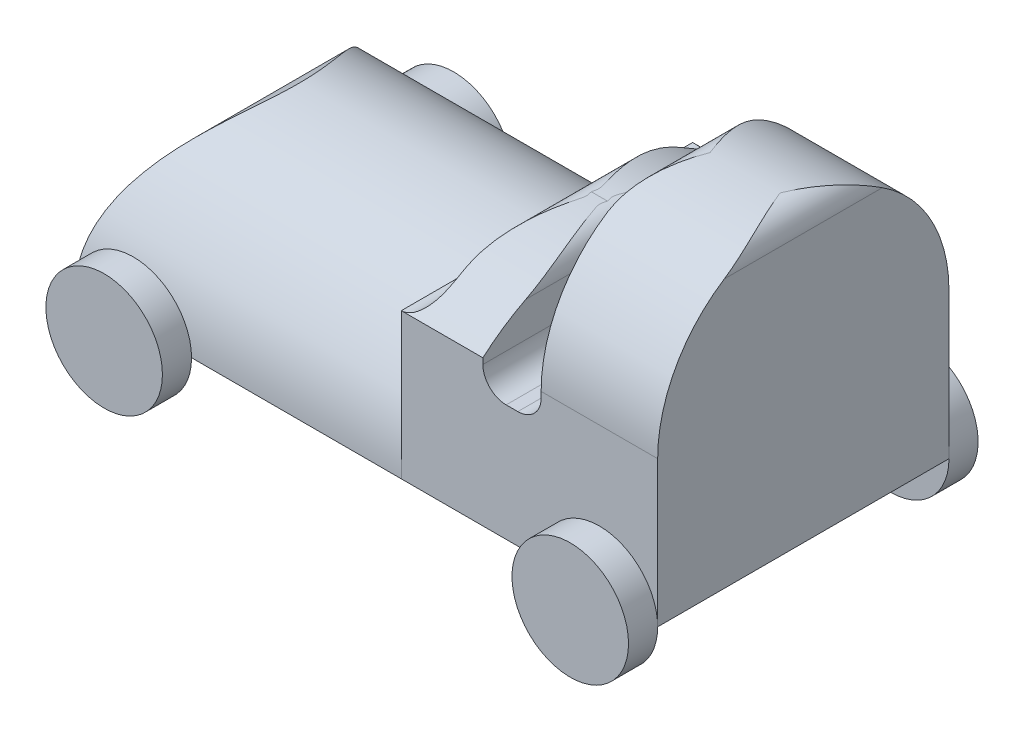
from build123d import *

# Parameters (mm, degrees)
SKETCH1_W               = 50
SKETCH1_H               = 25
BOSS_EXTRUDE1_DEPTH     = 25
CUT_EXTRUDE2_DEPTH      = 25
CUT_EXTRUDE3_DEPTH      = 49.79805324
CUT_EXTRUDE3_DEPTH_BACK = 49.79805324
CUT_EXTRUDE5_DEPTH      = 3
CUT_EXTRUDE5_DEPTH_BACK = 28
CUT_EXTRUDE9_DEPTH      = 7
SKETCH9_R               = 5
BOSS_EXTRUDE2_DEPTH     = 2.5
SKETCH10_R              = 5
BOSS_EXTRUDE3_DEPTH     = 2.5


with BuildPart() as part:
    # Sketch1 → Boss-Extrude1 (new body)
    with BuildSketch(Plane.XY):
        Rectangle(SKETCH1_W, SKETCH1_H)
    extrude(amount=BOSS_EXTRUDE1_DEPTH)

    # Sketch2 → Cut-Extrude2 (cut)
    with BuildSketch(Plane.XY.offset(25)):
        with BuildLine():
            Line((-25, 12.5), (-25, -12.5))
            ThreePointArc((-25, -12.5), (-23.216910184, -5.406814173), (-18.291561976, 0))
            Line((-18.291561976, 0), (3, 0))
            ThreePointArc((3, 0), (4.414213562, 0.585786438), (5, 2))
            Line((5, 2), (5, 2.5))
            ThreePointArc((5, 2.5), (5.585786438, 3.914213562), (7, 4.5))
            Line((7, 4.5), (8, 4.5))
            ThreePointArc((8, 4.5), (9.414213562, 3.914213562), (10, 2.5))
            Line((10, 2.5), (10, -0.5))
            ThreePointArc((10, -0.5), (10.585786438, -1.914213562), (12, -2.5))
            Line((12, -2.5), (13, -2.5))
            ThreePointArc((13, -2.5), (14.414213562, -1.914213562), (15, -0.5))
            Line((15, -0.5), (15, 10.5))
            ThreePointArc((15, 10.5), (15.585786438, 11.914213562), (17, 12.5))
            Line((17, 12.5), (-25, 12.5))
        make_face()
        with BuildLine():
            Line((25, 12.5), (23, 12.5))
            ThreePointArc((23, 12.5), (24.414213562, 11.914213562), (25, 10.5))
            Line((25, 10.5), (25, 12.5))
        make_face()
    extrude(amount=-CUT_EXTRUDE2_DEPTH, mode=Mode.SUBTRACT)

    # Sketch5 → Cut-Extrude3 (cut, two sides)
    with BuildSketch(Plane.ZY.offset(-15)) as cut_extrude3_sk:
        with BuildLine():
            Line((0, 12.5), (0, 10.5))
            Line((0, 10.5), (5.717670017, 10.5))
            ThreePointArc((5.717670017, 10.5), (8.964466094, 11.989578808), (12.5, 12.5))
            Line((12.5, 12.5), (0, 12.5))
        make_face()
        with BuildLine():
            Line((0, 10.5), (0, 0))
            ThreePointArc((0, 0), (1.522087521, 5.977912479), (5.717670017, 10.5))
            Line((5.717670017, 10.5), (0, 10.5))
        make_face()
        with BuildLine():
            ThreePointArc((19.282329983, 10.5), (23.477912479, 5.977912479), (25, 0))
            Line((25, 0), (25, 10.5))
            Line((25, 10.5), (19.282329983, 10.5))
        make_face()
        with BuildLine():
            Line((19.282329983, 10.5), (25, 10.5))
            Line((25, 10.5), (25, 12.5))
            Line((25, 12.5), (12.5, 12.5))
            ThreePointArc((12.5, 12.5), (16.035533906, 11.989578808), (19.282329983, 10.5))
        make_face()
    extrude(amount=CUT_EXTRUDE3_DEPTH, mode=Mode.SUBTRACT)
    extrude(cut_extrude3_sk.sketch, amount=-CUT_EXTRUDE3_DEPTH_BACK, mode=Mode.SUBTRACT)

    # Sketch7 → Cut-Extrude5 (cut, two sides)
    with BuildSketch(Plane(origin=(0, 0, 0), x_dir=(0, 0, -1), z_dir=(1, 0, 0))) as cut_extrude5_sk:
        with BuildLine():
            ThreePointArc((-25, -12.5), (-21.338834788, -3.661165258), (-12.500000066, 0))
            Line((-12.500000066, 0), (-25, 0))
            Line((-25, 0), (-25, -12.5))
        make_face()
        with BuildLine():
            ThreePointArc((-12.500000066, 0), (-3.661165258, -3.661165212), (0, -12.5))
            Line((0, -12.5), (0, 0))
            Line((0, 0), (-12.500000066, 0))
        make_face()
    extrude(amount=CUT_EXTRUDE5_DEPTH, mode=Mode.SUBTRACT)
    extrude(cut_extrude5_sk.sketch, amount=-CUT_EXTRUDE5_DEPTH_BACK, mode=Mode.SUBTRACT)

    # Sketch8 → Cut-Extrude9 (cut)
    with BuildSketch(Plane.ZY.offset(-3)):
        with BuildLine():
            Line((0, 6.612766069), (0, 4.490426703))
            Line((0, 4.490426703), (11.453744839, 4.490426703))
            ThreePointArc((11.453744839, 4.490426703), (11.97687242, 4.497948677), (12.5, 4.490426703))
            Line((12.5, 4.490426703), (12.5, 6.612766069))
            Line((12.5, 6.612766069), (0, 6.612766069))
        make_face()
        with BuildLine():
            Line((0, 4.490426703), (0, 0))
            ThreePointArc((0, 0), (5.335827096, 3.24265383), (11.453744839, 4.490426703))
            Line((11.453744839, 4.490426703), (0, 4.490426703))
        make_face()
        with BuildLine():
            Line((12.5, 6.612766069), (12.5, 4.490426703))
            ThreePointArc((12.5, 4.490426703), (13.02312758, 4.497948677), (13.546255161, 4.490426703))
            Line((13.546255161, 4.490426703), (25, 4.490426703))
            Line((25, 4.490426703), (25, 6.612766069))
            Line((25, 6.612766069), (12.5, 6.612766069))
        make_face()
        with BuildLine():
            ThreePointArc((13.546255161, 4.490426703), (19.664172904, 3.24265383), (25, 0))
            Line((25, 0), (25, 4.490426703))
            Line((25, 4.490426703), (13.546255161, 4.490426703))
        make_face()
    extrude(amount=-CUT_EXTRUDE9_DEPTH, mode=Mode.SUBTRACT)

    # Sketch9 → Boss-Extrude2 (add)
    with BuildSketch(Plane.XY.offset(25)):
        with Locations((-20, -12.5)):
            Circle(SKETCH9_R)
        with Locations((20, -12.5)):
            Circle(SKETCH9_R)
    extrude(amount=BOSS_EXTRUDE2_DEPTH)


with BuildPart() as boss_extrude2_piece_1:
    # of the separate pieces the step leaves, piece 1, a body of its own (boss_extrude2_pieces)
    add(part.part.solids().sort_by_distance((15, 10.5, 5.717670017))[0])

    # Sketch10 → Boss-Extrude3 (add)
    with BuildSketch(Plane(origin=(0, 0, 0), x_dir=(-1, 0, 0), z_dir=(0, 0, -1))):
        with Locations(Location((-20, -12.5, 0), (0, 0, 180))):
            Circle(SKETCH10_R)
        with Locations((20, -12.5)):
            Circle(SKETCH10_R)
    extrude(amount=BOSS_EXTRUDE3_DEPTH)


with BuildPart() as boss_extrude2_piece_2:
    # of the separate pieces the step leaves, piece 2, a body of its own (boss_extrude2_pieces)
    add(part.part.solids().sort_by_distance((-15, -12.5, 27.5))[0])


with BuildPart() as boss_extrude3_piece_1:
    # of the separate pieces the step leaves, piece 1, a body of its own (boss_extrude3_pieces)
    add(boss_extrude2_piece_1.part.solids().sort_by_distance((15, 10.5, 5.717670017))[0])


with BuildPart() as boss_extrude3_piece_2:
    # of the separate pieces the step leaves, piece 2, a body of its own (boss_extrude3_pieces)
    add(boss_extrude2_piece_1.part.solids().sort_by_distance((-25, -12.5, -2.5))[0])


solid = Compound([boss_extrude2_piece_2.part, boss_extrude3_piece_1.part, boss_extrude3_piece_2.part])
